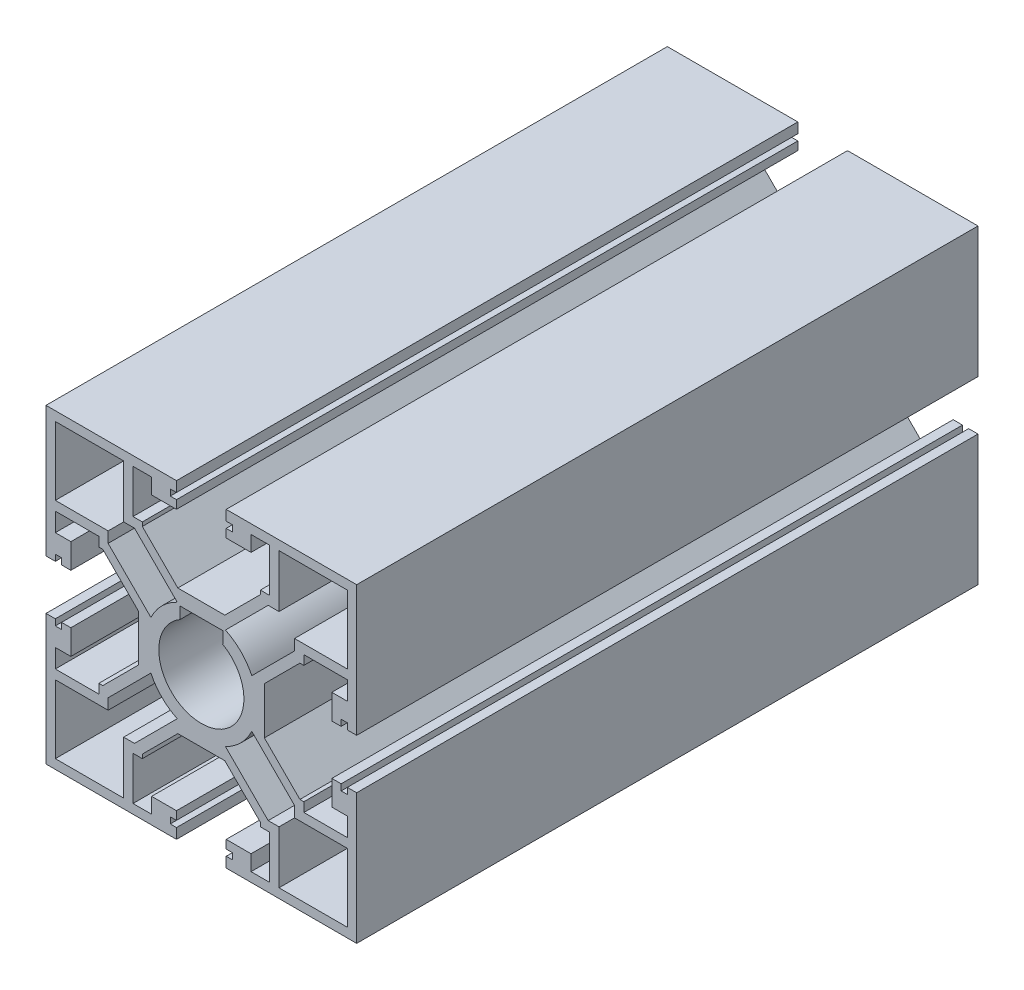
from build123d import *

# Parameters (mm, degrees)
SKETCH_A01_1_R     = 6.85
EXTRUDE1_DEPTH     = 100
SKETCH1_W          = 6.892084618
SKETCH1_H          = 1.884433334
CUT_EXTRUDE1_DEPTH = 101


with BuildPart() as part:
    # Sketch A01-1 → Extrude1 (new body)
    with BuildSketch(Plane.XY):
        Polygon((-23.5, 4), (-25, 4), (-25, 25), (-4, 25), (-4, 23.349803168), (-5, 23.349803168), (-5, 22.349803168), (-4, 22.349803168), (-4, 21), (-8, 21), (-8, 23.5), (-11, 23.5), (-11, 21), (-11, 16.5), (-9.5, 16.5), (-9.5, 15.863961), (-3.78206785, 10.14602885), (3.78206785, 10.14602885), (9.5, 15.863961), (9.5, 16.5), (11, 16.5), (11, 21), (11, 23.5), (8, 23.5), (8, 21), (4, 21), (4, 22.349803168), (5, 22.349803168), (5, 23.349803168), (4, 23.349803168), (4, 25), (25, 25), (25, 4), (23.5, 4), (23.5, 5), (22.5, 5), (22.5, 4), (21, 4), (21, 8), (23.5, 8), (23.5, 11), (21, 11), (16.5, 11), (16.5, 9.5), (15.863961, 9.5), (10.14602885, 3.78206785), (10.14602885, -3.78206785), (15.863961, -9.5), (16.5, -9.5), (16.5, -11), (21, -11), (23.5, -11), (23.5, -8), (21, -8), (21, -4), (22.5, -4), (22.5, -5), (23.5, -5), (23.5, -4), (25, -4), (25, -25), (4, -25), (4, -23.349803168), (5, -23.349803168), (5, -22.349803168), (4, -22.349803168), (4, -21), (8, -21), (8, -23.5), (11, -23.5), (11, -21), (11, -16.5), (9.5, -16.5), (9.5, -15.863961), (3.78206785, -10.14602885), (-3.78206785, -10.14602885), (-9.5, -15.863961), (-9.5, -16.5), (-11, -16.5), (-11, -21), (-11, -23.5), (-8, -23.5), (-8, -21), (-4, -21), (-4, -22.349803168), (-5, -22.349803168), (-5, -23.349803168), (-4, -23.349803168), (-4, -25), (-25, -25), (-25, -4), (-23.5, -4), (-23.5, -5), (-22.5, -5), (-22.5, -4), (-21, -4), (-21, -8), (-23.5, -8), (-23.5, -11), (-21, -11), (-16.5, -11), (-16.5, -9.5), (-15.863961, -9.5), (-10.14602885, -3.78206785), (-10.14602885, 3.78206785), (-15.863961, 9.5), (-16.5, 9.5), (-16.5, 11), (-21, 11), (-23.5, 11), (-23.5, 8), (-21, 8), (-21, 4), (-22.5, 4), (-22.5, 5), (-23.5, 5), align=None)
        Circle(SKETCH_A01_1_R, mode=Mode.SUBTRACT)
        with BuildLine():
            Line((-23.5, 23.5), (-23.5, 12.5))
            Line((-23.5, 12.5), (-15, 12.5))
            Line((-15, 12.5), (-15, 10.757359344))
            Line((-15, 10.757359344), (-8.121320334, 3.878679677))
            ThreePointArc((-8.121320334, 3.878679677), (-6.363961031, 6.363961031), (-3.878679677, 8.121320334))
            Line((-3.878679677, 8.121320334), (-10.757359344, 15))
            Line((-10.757359344, 15), (-12.5, 15))
            Line((-12.5, 15), (-12.5, 23.5))
            Line((-12.5, 23.5), (-23.5, 23.5))
        make_face(mode=Mode.SUBTRACT)
        with BuildLine():
            Line((10.757359344, 15), (12.5, 15))
            Line((12.5, 15), (12.5, 23.5))
            Line((12.5, 23.5), (23.5, 23.5))
            Line((23.5, 23.5), (23.5, 12.5))
            Line((23.5, 12.5), (15, 12.5))
            Line((15, 12.5), (15, 10.757359344))
            Line((15, 10.757359344), (8.121320334, 3.878679677))
            ThreePointArc((8.121320334, 3.878679677), (6.363961031, 6.363961031), (3.878679677, 8.121320334))
            Line((3.878679677, 8.121320334), (10.757359344, 15))
        make_face(mode=Mode.SUBTRACT)
        with BuildLine():
            Line((23.5, -23.5), (23.5, -12.5))
            Line((23.5, -12.5), (15, -12.5))
            Line((15, -12.5), (15, -10.757359344))
            Line((15, -10.757359344), (8.121320334, -3.878679677))
            ThreePointArc((8.121320334, -3.878679677), (6.363961031, -6.363961031), (3.878679677, -8.121320334))
            Line((3.878679677, -8.121320334), (10.757359344, -15))
            Line((10.757359344, -15), (12.5, -15))
            Line((12.5, -15), (12.5, -23.5))
            Line((12.5, -23.5), (23.5, -23.5))
        make_face(mode=Mode.SUBTRACT)
        with BuildLine():
            Line((-10.757359344, -15), (-12.5, -15))
            Line((-12.5, -15), (-12.5, -23.5))
            Line((-12.5, -23.5), (-23.5, -23.5))
            Line((-23.5, -23.5), (-23.5, -12.5))
            Line((-23.5, -12.5), (-15, -12.5))
            Line((-15, -12.5), (-15, -10.757359344))
            Line((-15, -10.757359344), (-8.121320334, -3.878679677))
            ThreePointArc((-8.121320334, -3.878679677), (-6.363961031, -6.363961031), (-3.878679677, -8.121320334))
            Line((-3.878679677, -8.121320334), (-10.757359344, -15))
        make_face(mode=Mode.SUBTRACT)
    extrude(amount=-EXTRUDE1_DEPTH)

    # Sketch1 → Cut-Extrude1 (cut, through all)
    with BuildSketch(Plane.XY):
        with Locations((0.028776834, 6.878949495)):
            Rectangle(SKETCH1_W, SKETCH1_H)
    extrude(amount=-CUT_EXTRUDE1_DEPTH, mode=Mode.SUBTRACT)


solid = part.part
